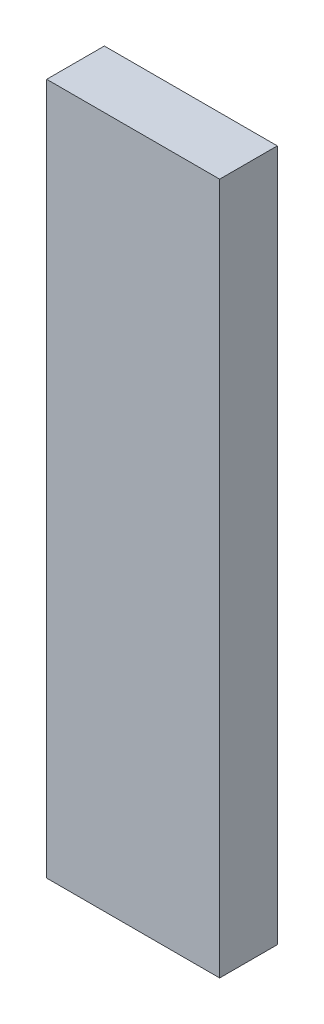
from build123d import *

# Parameters (mm, degrees)
SKETCH_1_W      = 0.9
SKETCH_1_H      = 3.6
EXTRUDE_1_DEPTH = 0.3


with BuildPart() as part:
    # Эскиз1 → Бобышка-Вытянуть1 (new body)
    with BuildSketch(Plane.XY):
        Rectangle(SKETCH_1_W, SKETCH_1_H)
    extrude(amount=EXTRUDE_1_DEPTH)


solid = part.part
